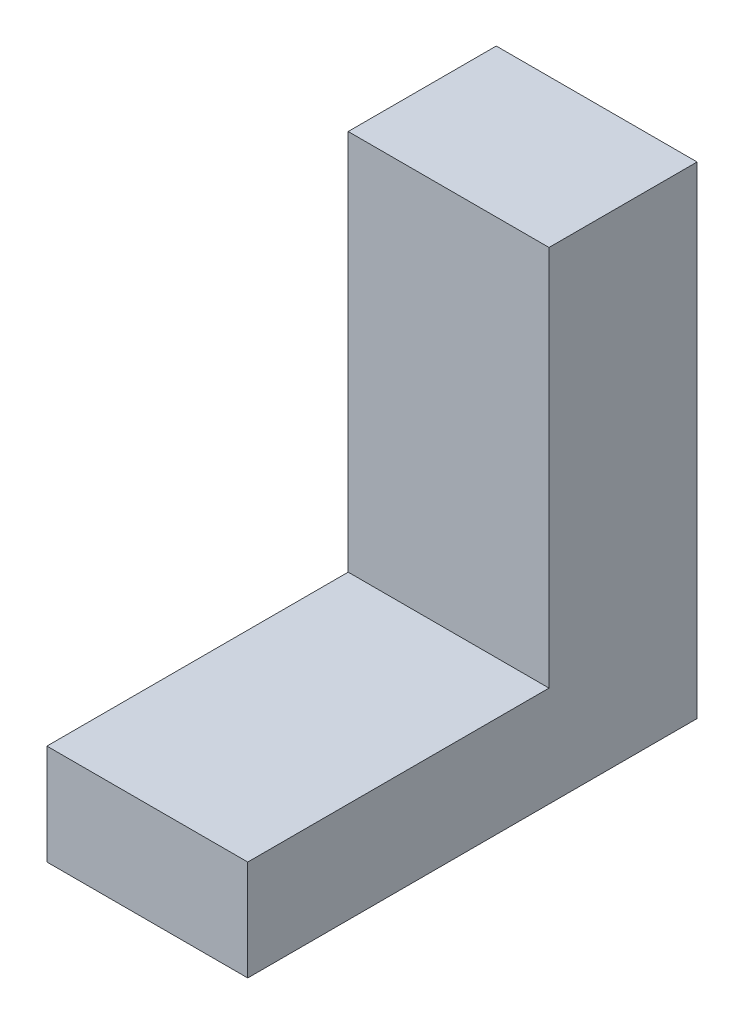
from build123d import *

# Parameters (mm, degrees)
BOSS_EXTRUDE1_DEPTH = 508


with BuildPart() as part:
    # Sketch1 → Boss-Extrude1 (new body)
    with BuildSketch(Plane(origin=(0, 0, 0), x_dir=(0, 0, -1), z_dir=(1, 0, 0))):
        Polygon((0, 0), (-762, 0), (-762, -254), (0, -254), (374.542372881, -254), (374.542372881, 965.2), (0, 965.2), align=None)
    extrude(amount=BOSS_EXTRUDE1_DEPTH)


solid = part.part
